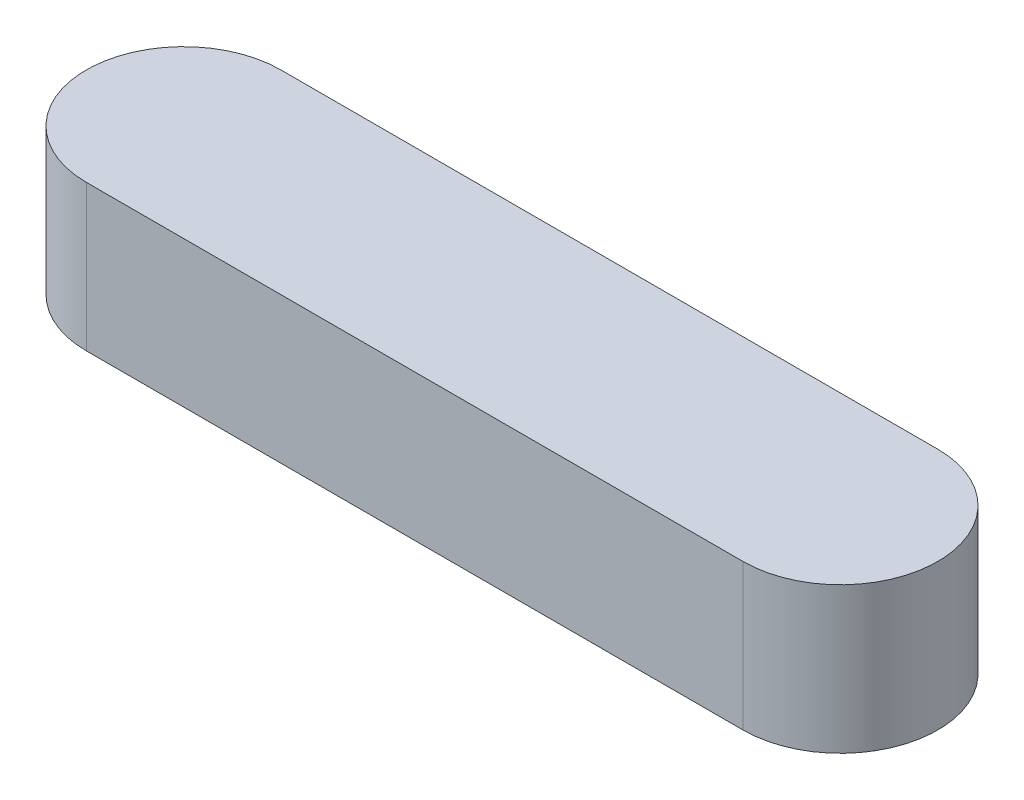
from build123d import *

# Parameters (mm, degrees)
BOSS_EXTRUDE1_DEPTH = 12


with BuildPart() as part:
    # Sketch1 → Boss-Extrude1 (new body)
    with BuildSketch(Plane(origin=(0, 0, 0), x_dir=(1, 0, 0), z_dir=(0, 1, 0))):
        with BuildLine():
            Line((-27, 8), (27, 8))
            ThreePointArc((27, 8), (35, 0), (27, -8))
            Line((27, -8), (-27, -8))
            ThreePointArc((-27, -8), (-35, 0), (-27, 8))
        make_face()
    extrude(amount=BOSS_EXTRUDE1_DEPTH)


solid = part.part
